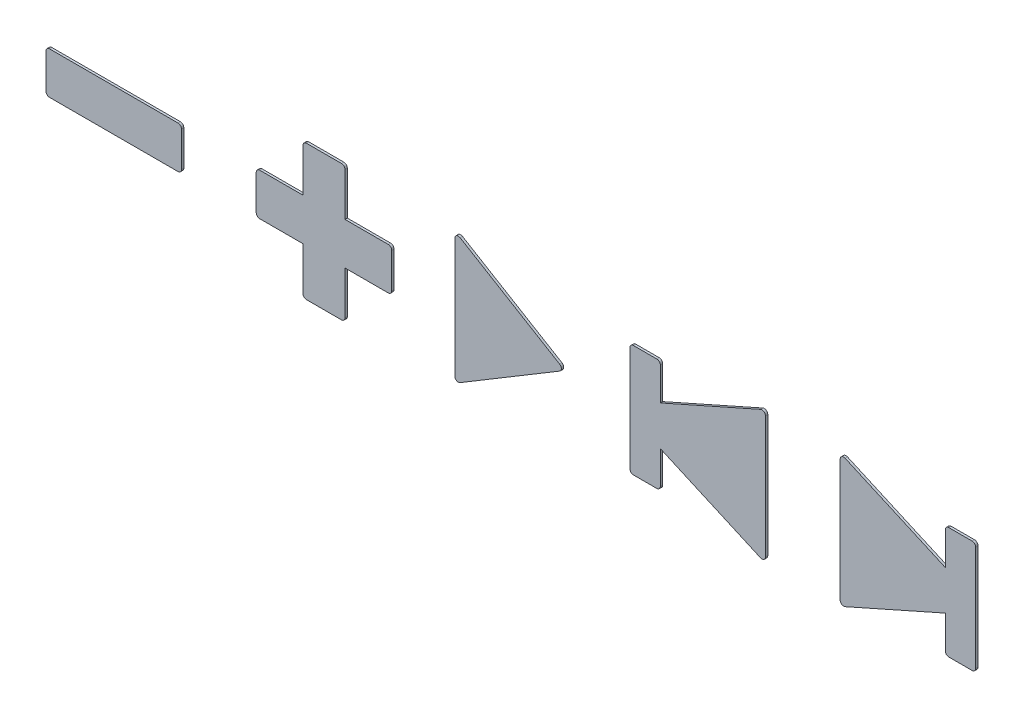
from build123d import *

# Parameters (mm, degrees)
BOSS_EXTRUDE1_DEPTH   = 0.2
BOSS_EXTRUDE1_2_DEPTH = 0.2
BOSS_EXTRUDE1_3_DEPTH = 0.2
BOSS_EXTRUDE1_4_DEPTH = 0.2
BOSS_EXTRUDE1_5_DEPTH = 0.2


with BuildPart() as part:
    # Sketch2 → Boss-Extrude1 (new body)
    with BuildSketch(Plane.XY):
        with BuildLine():
            Line((-4.8, 5.116904811), (-4.8, -5.116904811))
            ThreePointArc((-4.8, -5.116904811), (-4.647809644, -5.377964783), (-4.345651273, -5.374152688))
            Line((-4.345651273, -5.374152688), (4.182523411, -0.257247878))
            ThreePointArc((4.182523411, -0.257247878), (4.328174684, 0), (4.182523411, 0.257247878))
            Line((4.182523411, 0.257247878), (-4.345651273, 5.374152688))
            ThreePointArc((-4.345651273, 5.374152688), (-4.647809644, 5.377964783), (-4.8, 5.116904811))
        make_face()
    extrude(amount=BOSS_EXTRUDE1_DEPTH)


with BuildPart() as body_2:
    # Sketch2 → Boss-Extrude1 2 (new body)
    with BuildSketch(Plane.XY):
        with BuildLine():
            Line((-10.2, -1.5), (-10.2, 1.5))
            ThreePointArc((-10.2, 1.5), (-10.287867966, 1.712132034), (-10.5, 1.8))
            Line((-10.5, 1.8), (-14.2, 1.8))
            Line((-14.2, 1.8), (-14.2, 5.5))
            ThreePointArc((-14.2, 5.5), (-14.287867966, 5.712132034), (-14.5, 5.8))
            Line((-14.5, 5.8), (-17.5, 5.8))
            ThreePointArc((-17.5, 5.8), (-17.712132034, 5.712132034), (-17.8, 5.5))
            Line((-17.8, 5.5), (-17.8, 1.8))
            Line((-17.8, 1.8), (-21.5, 1.8))
            ThreePointArc((-21.5, 1.8), (-21.712132034, 1.712132034), (-21.8, 1.5))
            Line((-21.8, 1.5), (-21.8, -1.5))
            ThreePointArc((-21.8, -1.5), (-21.712132034, -1.712132034), (-21.5, -1.8))
            Line((-21.5, -1.8), (-17.8, -1.8))
            Line((-17.8, -1.8), (-17.8, -5.5))
            ThreePointArc((-17.8, -5.5), (-17.712132034, -5.712132034), (-17.5, -5.8))
            Line((-17.5, -5.8), (-14.5, -5.8))
            ThreePointArc((-14.5, -5.8), (-14.287867966, -5.712132034), (-14.2, -5.5))
            Line((-14.2, -5.5), (-14.2, -1.8))
            Line((-14.2, -1.8), (-10.5, -1.8))
            ThreePointArc((-10.5, -1.8), (-10.287867966, -1.712132034), (-10.2, -1.5))
        make_face()
    extrude(amount=BOSS_EXTRUDE1_2_DEPTH)


with BuildPart() as body_3:
    # Sketch2 → Boss-Extrude1 3 (new body)
    with BuildSketch(Plane.XY):
        with BuildLine():
            Line((-28.2, 1.5), (-28.2, -1.5))
            ThreePointArc((-28.2, -1.5), (-28.287867966, -1.712132034), (-28.5, -1.8))
            Line((-28.5, -1.8), (-39.5, -1.8))
            ThreePointArc((-39.5, -1.8), (-39.712132034, -1.712132034), (-39.8, -1.5))
            Line((-39.8, -1.5), (-39.8, 1.5))
            ThreePointArc((-39.8, 1.5), (-39.712132034, 1.712132034), (-39.5, 1.8))
            Line((-39.5, 1.8), (-28.5, 1.8))
            ThreePointArc((-28.5, 1.8), (-28.287867966, 1.712132034), (-28.2, 1.5))
        make_face()
    extrude(amount=BOSS_EXTRUDE1_3_DEPTH)


with BuildPart() as body_4:
    # Sketch2 → Boss-Extrude1 4 (new body)
    with BuildSketch(Plane.XY):
        with BuildLine():
            Line((10.2, 4.5), (10.2, -4.5))
            ThreePointArc((10.2, -4.5), (10.287867966, -4.712132034), (10.5, -4.8))
            Line((10.5, -4.8), (12.5, -4.8))
            ThreePointArc((12.5, -4.8), (12.712132034, -4.712132034), (12.8, -4.5))
            Line((12.8, -4.5), (12.8, -1.692247604))
            Line((12.8, -1.692247604), (21.37815846, -5.504762476))
            ThreePointArc((21.37815846, -5.504762476), (21.663474062, -5.482166682), (21.8, -5.230619011))
            Line((21.8, -5.230619011), (21.8, 5.230619011))
            ThreePointArc((21.8, 5.230619011), (21.663474062, 5.482166682), (21.37815846, 5.504762476))
            Line((21.37815846, 5.504762476), (12.8, 1.692247604))
            Line((12.8, 1.692247604), (12.8, 4.5))
            ThreePointArc((12.8, 4.5), (12.712132034, 4.712132034), (12.5, 4.8))
            Line((12.5, 4.8), (10.5, 4.8))
            ThreePointArc((10.5, 4.8), (10.287867966, 4.712132034), (10.2, 4.5))
        make_face()
    extrude(amount=BOSS_EXTRUDE1_4_DEPTH)


with BuildPart() as body_5:
    # Sketch2 → Boss-Extrude1 5 (new body)
    with BuildSketch(Plane.XY):
        with BuildLine():
            Line((28.2, 5.230619011), (28.2, -5.230619011))
            ThreePointArc((28.2, -5.230619011), (28.336525938, -5.482166682), (28.62184154, -5.504762476))
            Line((28.62184154, -5.504762476), (37.2, -1.692247604))
            Line((37.2, -1.692247604), (37.2, -4.5))
            ThreePointArc((37.2, -4.5), (37.287867966, -4.712132034), (37.5, -4.8))
            Line((37.5, -4.8), (39.5, -4.8))
            ThreePointArc((39.5, -4.8), (39.712132034, -4.712132034), (39.8, -4.5))
            Line((39.8, -4.5), (39.8, 4.5))
            ThreePointArc((39.8, 4.5), (39.712132034, 4.712132034), (39.5, 4.8))
            Line((39.5, 4.8), (37.5, 4.8))
            ThreePointArc((37.5, 4.8), (37.287867966, 4.712132034), (37.2, 4.5))
            Line((37.2, 4.5), (37.2, 1.692247604))
            Line((37.2, 1.692247604), (28.62184154, 5.504762476))
            ThreePointArc((28.62184154, 5.504762476), (28.336525938, 5.482166682), (28.2, 5.230619011))
        make_face()
    extrude(amount=BOSS_EXTRUDE1_5_DEPTH)


solid = Compound([part.part, body_2.part, body_3.part, body_4.part, body_5.part])
